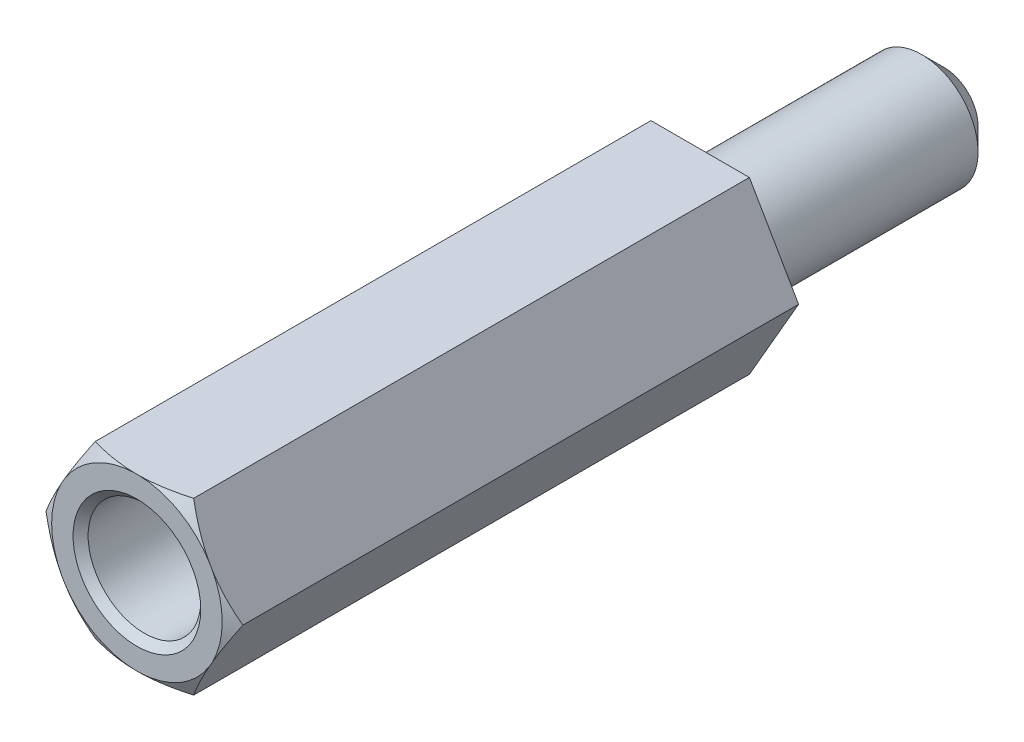
from build123d import *

# Parameters (mm, degrees)
BOSS_EXTRUDE1_DEPTH     = 15
SKETCH2_R               = 1.5
CUT_EXTRUDE1_DEPTH      = 1
CUT_EXTRUDE1_DEPTH_BACK = 12
CHAMFER1_SIZE           = 0.2
SKETCH4_R               = 1.5
BOSS_EXTRUDE2_DEPTH     = 6.5
CHAMFER2_SIZE           = 0.6


with BuildPart() as part:
    # Sketch1 → Boss-Extrude1 (new body)
    with BuildSketch(Plane.XY):
        Polygon((2.621170222, 0), (1.310585111, 2.27), (-1.310585111, 2.27), (-2.621170222, 0), (-1.310585111, -2.27), (1.310585111, -2.27), align=None)
    extrude(amount=BOSS_EXTRUDE1_DEPTH)

    # Sketch2 → Cut-Extrude1 (cut, two sides)
    with BuildSketch(Plane.XY.offset(15)) as cut_extrude1_sk:
        Circle(SKETCH2_R)
    extrude(amount=CUT_EXTRUDE1_DEPTH, mode=Mode.SUBTRACT)
    extrude(cut_extrude1_sk.sketch, amount=-CUT_EXTRUDE1_DEPTH_BACK, mode=Mode.SUBTRACT)

    # Sketch3 → Cut-Revolve1 (revolve, cut)
    with BuildSketch(Plane(origin=(0, 0, 0), x_dir=(1, 0, 0), z_dir=(0, 1, 0))):
        Polygon((-2.621170222, -15), (-2.271170222, -15), (-2.621170222, -14.8), align=None)
    revolve(axis=Axis((0, 0, 3), (0, 0, 1)), mode=Mode.SUBTRACT)

    # Chamfer1
    chamfer1_edges = [part.edges().sort_by_distance(p)[0] for p in [
        (-1.5, 0, 15),
    ]]
    chamfer(chamfer1_edges, length=CHAMFER1_SIZE)

    # Sketch4 → Boss-Extrude2 (add)
    with BuildSketch(Plane(origin=(0, 0, 0), x_dir=(-1, 0, 0), z_dir=(0, 0, -1))):
        Circle(SKETCH4_R)
    extrude(amount=BOSS_EXTRUDE2_DEPTH)

    # Chamfer2
    chamfer2_edges = [part.edges().sort_by_distance(p)[0] for p in [
        (1.5, 0, -6.5),
    ]]
    chamfer(chamfer2_edges, length=CHAMFER2_SIZE)


solid = part.part
